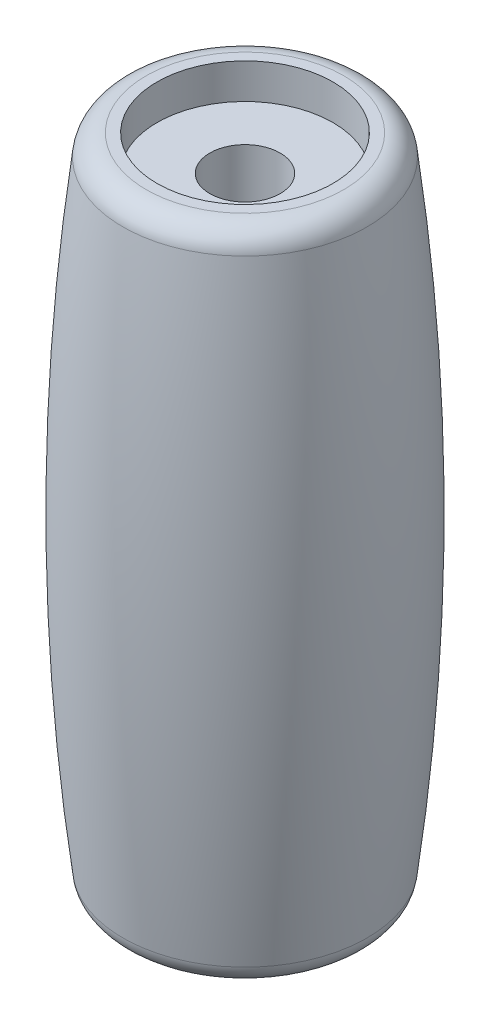
from build123d import *

# Parameters (mm, degrees)
SKETCH2_R          = 3.75
CUT_EXTRUDE1_DEPTH = 1.5
SKETCH3_R          = 3.75
CUT_EXTRUDE2_DEPTH = 1.5
SKETCH4_R          = 1.5
CUT_EXTRUDE3_DEPTH = 27.5


with BuildPart() as part:
    # Sketch1 → Revolve1 (revolve)
    with BuildSketch(Plane.XY):
        with BuildLine():
            Line((0, 0), (-4.209254706, 0))
            ThreePointArc((-4.209254706, 0), (-4.872125478, 0.251266175), (-5.201882242, 0.87879532))
            ThreePointArc((-5.201882242, 0.87879532), (-6, 14), (-5.201882242, 27.12120468))
            ThreePointArc((-5.201882242, 27.12120468), (-4.872125478, 27.748733825), (-4.209254706, 28))
            Line((-4.209254706, 28), (0, 28))
            Line((0, 28), (0, 0))
        make_face()
    revolve(axis=Axis((0, 0, 0), (0, 1, 0)))

    # Sketch2 → Cut-Extrude1 (cut)
    with BuildSketch(Plane(origin=(0, 28, 0), x_dir=(1, 0, 0), z_dir=(0, 1, 0))):
        Circle(SKETCH2_R)
    extrude(amount=-CUT_EXTRUDE1_DEPTH, mode=Mode.SUBTRACT)

    # Sketch3 → Cut-Extrude2 (cut)
    with BuildSketch(Plane.XZ):
        Circle(SKETCH3_R)
    extrude(amount=-CUT_EXTRUDE2_DEPTH, mode=Mode.SUBTRACT)

    # Sketch4 → Cut-Extrude3 (cut, through all)
    with BuildSketch(Plane(origin=(0, 1.5, 0), x_dir=(-1, 0, 0), z_dir=(0, -1, 0))):
        Circle(SKETCH4_R)
    extrude(amount=-CUT_EXTRUDE3_DEPTH, mode=Mode.SUBTRACT)


solid = part.part
